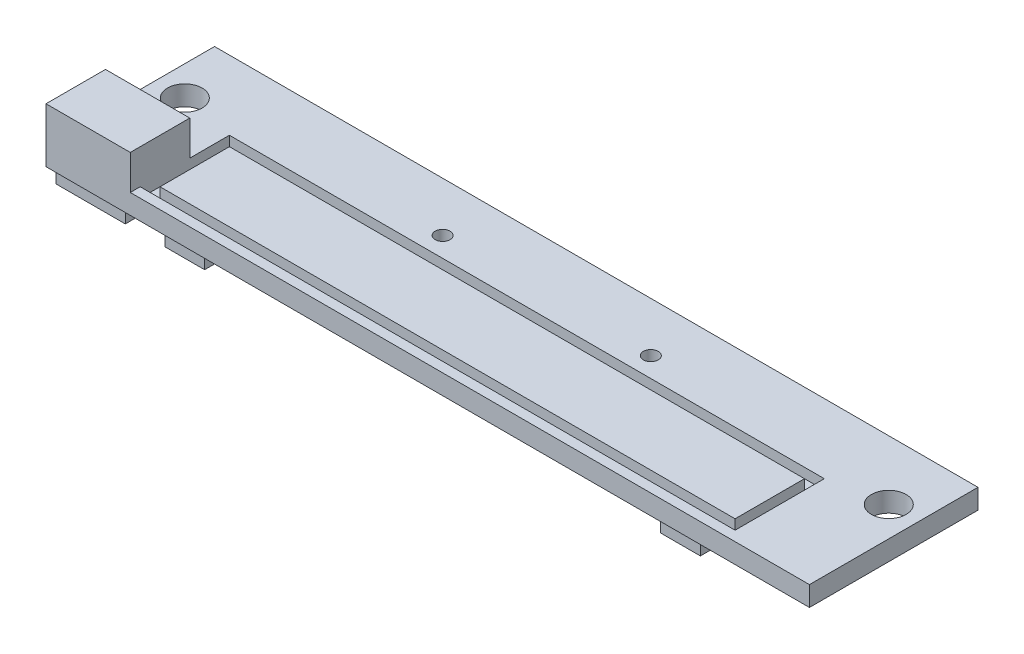
from build123d import *

# Parameters (mm, degrees)
ESQUISSE1_W             = 77
ESQUISSE1_H             = 17
BOSS_EXTRU_1_DEPTH      = 2
ESQUISSE2_W             = 60
ESQUISSE2_H             = 9
ESQUISSE2_W_2           = 58
ESQUISSE2_H_2           = 7
ENL_V_MAT_EXTRU_1_DEPTH = 1
ESQUISSE3_W             = 8.5
ESQUISSE3_H             = 6
BOSS_EXTRU_2_DEPTH      = 3.5
ESQUISSE4_R             = 1.75
ESQUISSE4_R_2           = 0.75
ENL_V_MAT_EXTRU_2_DEPTH = 3
ESQUISSE5_W             = 7
ESQUISSE5_H             = 2.5
ESQUISSE5_W_2           = 2.5
ESQUISSE5_H_2           = 5.5
ESQUISSE5_W_3           = 4
ESQUISSE5_H_3           = 3
BOSS_EXTRU_3_DEPTH      = 1.5


with BuildPart() as part:
    # Esquisse1 → Boss.-Extru.1 (new body)
    with BuildSketch(Plane(origin=(0, 0, 0), x_dir=(1, 0, 0), z_dir=(0, 1, 0))):
        with Locations((38.5, 8.5)):
            Rectangle(ESQUISSE1_W, ESQUISSE1_H)
    extrude(amount=BOSS_EXTRU_1_DEPTH)

    # Esquisse2 → Enlèv. mat.-Extru.1 (cut)
    with BuildSketch(Plane(origin=(0, 2, 0), x_dir=(1, 0, 0), z_dir=(0, 1, 0))):
        with Locations((38.5, 5.5)):
            Rectangle(ESQUISSE2_W, ESQUISSE2_H)
        with Locations((38.5, 5.5)):
            Rectangle(ESQUISSE2_W_2, ESQUISSE2_H_2, mode=Mode.SUBTRACT)
    extrude(amount=-ENL_V_MAT_EXTRU_1_DEPTH, mode=Mode.SUBTRACT)

    # Esquisse3 → Boss.-Extru.2 (add)
    with BuildSketch(Plane(origin=(0, 2, 0), x_dir=(1, 0, 0), z_dir=(0, 1, 0))):
        with Locations((4.25, 3)):
            Rectangle(ESQUISSE3_W, ESQUISSE3_H)
    extrude(amount=BOSS_EXTRU_2_DEPTH)

    # Esquisse4 → Enlèv. mat.-Extru.2 (cut, through all)
    with BuildSketch(Plane(origin=(0, 2, 0), x_dir=(1, 0, 0), z_dir=(0, 1, 0))):
        with Locations((74, 11)):
            Circle(ESQUISSE4_R)
        with Locations((49, 12)):
            Circle(ESQUISSE4_R_2)
        with Locations((3, 11)):
            Circle(ESQUISSE4_R)
        with Locations((28, 12)):
            Circle(ESQUISSE4_R_2)
    extrude(amount=-ENL_V_MAT_EXTRU_2_DEPTH, mode=Mode.SUBTRACT)

    # Esquisse5 → Boss.-Extru.3 (add)
    with BuildSketch(Plane.XZ):
        with Locations((4, -1.75)):
            Rectangle(ESQUISSE5_W, ESQUISSE5_H)
        with Locations((8.25, -5.85)):
            Rectangle(ESQUISSE5_W_2, ESQUISSE5_H_2)
        with Locations((15, -10.5)):
            Rectangle(ESQUISSE5_W_3, ESQUISSE5_H_3)
        with Locations((13.5, -2)):
            Rectangle(ESQUISSE5_W_3, ESQUISSE5_H_3)
        with Locations((68.75, -5.85)):
            Rectangle(ESQUISSE5_W_2, ESQUISSE5_H_2)
        with Locations((62, -10.5)):
            Rectangle(ESQUISSE5_W_3, ESQUISSE5_H_3)
        with Locations((63.5, -2)):
            Rectangle(ESQUISSE5_W_3, ESQUISSE5_H_3)
    extrude(amount=BOSS_EXTRU_3_DEPTH)


solid = part.part
